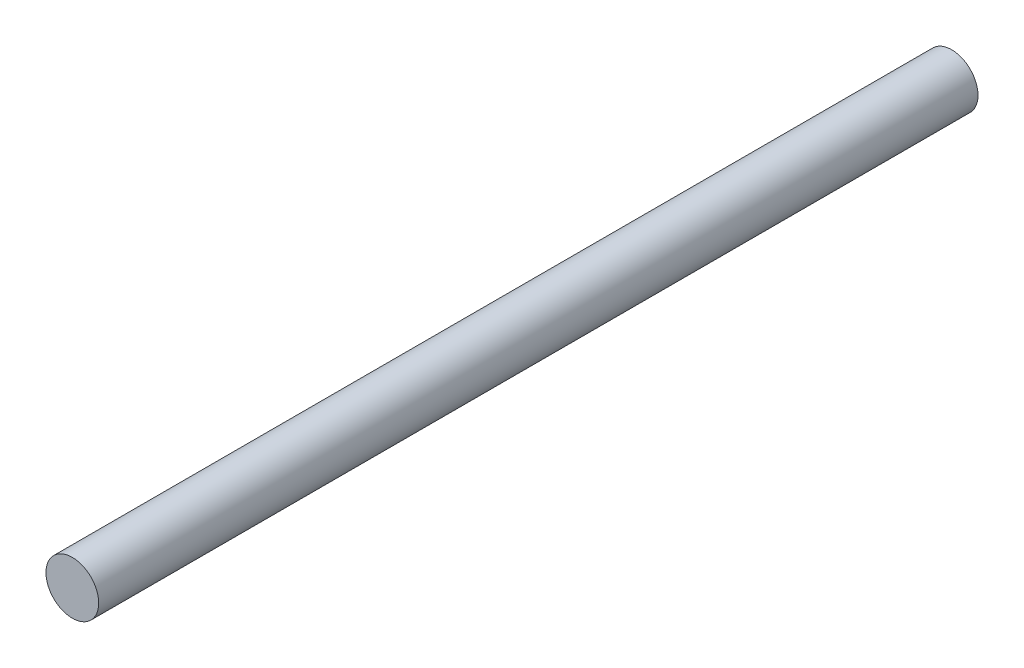
from build123d import *

# Parameters (mm, degrees)
SKETCH1_R           = 3
BOSS_EXTRUDE1_DEPTH = 100


with BuildPart() as part:
    # Sketch1 → Boss-Extrude1 (new body)
    with BuildSketch(Plane.XY):
        with Locations((0, 0.212314024)):
            Circle(SKETCH1_R)
    extrude(amount=BOSS_EXTRUDE1_DEPTH)


solid = part.part
